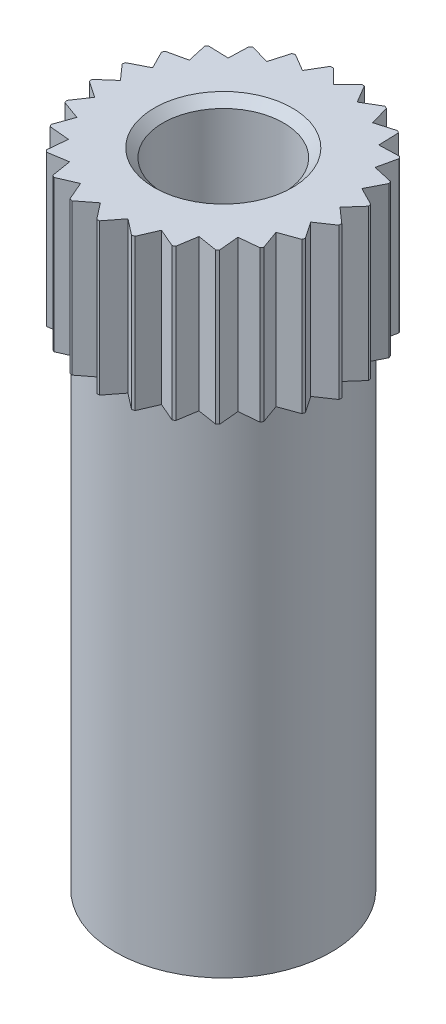
from build123d import *

# Parameters (mm, degrees)
SKETCH_1_R                  = 2.9
EXTRUDE_1_DEPTH             = 3.5
SKETCH_2_R                  = 2.5
EXTRUDE_2_DEPTH             = 11.4
CUT_EXTRUDE_1_DEPTH         = 4
HOLE_WIZARD_M32_D           = 2.8
HOLE_WIZARD_M32_DEPTH       = 6.9
HOLE_WIZARD_M32_CSINK_D     = 3.2
HOLE_WIZARD_M32_CSINK_ANGLE = 90
HOLE_WIZARD_M32_TIP         = 1.4


with BuildPart() as part:
    # Эскиз1 → Бобышка-Вытянуть1 (new body)
    with BuildSketch(Plane(origin=(0, 0, 0), x_dir=(1, 0, 0), z_dir=(0, 1, 0))):
        Circle(SKETCH_1_R)
    extrude(amount=EXTRUDE_1_DEPTH)

    # Эскиз2 → Бобышка-Вытянуть2 (add)
    with BuildSketch(Plane.XZ):
        Circle(SKETCH_2_R)
    extrude(amount=EXTRUDE_2_DEPTH)

    # Эскиз3 → Вырез-Вытянуть1 (cut)
    with BuildSketch(Plane(origin=(0, 3.5, 0), x_dir=(1, 0, 0), z_dir=(0, 1, 0))):
        Polygon((0, 2.55), (-0.366495157, 2.916495157), (0.366495157, 2.916495157), align=None)
        Polygon((0.634159212, 2.469887061), (0.370321814, 2.916011738), (1.080283889, 2.733724459), align=None)
        Polygon((1.228471869, 2.234582034), (1.083870103, 2.732304577), (1.726194412, 2.3791838), align=None)
        Polygon((1.74559512, 1.85887), (1.729314848, 2.37691667), (2.263641791, 1.875150272), align=None)
        Polygon((2.15303621, 1.366358327), (2.26610038, 1.872178348), (2.658856231, 1.253294157), align=None)
        Polygon((2.425194117, 0.787993336), (2.660498492, 1.249804175), (2.887004956, 0.55268896), align=None)
        Polygon((2.544968157, 0.160115825), (2.887727699, 0.548900209), (2.933752541, -0.182643716), align=None)
        Polygon((2.504832489, -0.477822352), (2.933510354, -0.186493176), (2.796161665, -0.906500217), align=None)
        Polygon((2.307308984, -1.085737193), (2.794969765, -0.910168509), (2.482877668, -1.573397974), align=None)
        Polygon((1.964808769, -1.625431174), (2.480810946, -1.576654607), (2.013585336, -2.141433351), align=None)
        Polygon((1.498852393, -2.062993336), (2.010773652, -2.144073698), (1.417772031, -2.574914594), align=None)
        Polygon((0.938717609, -2.370930039), (1.414392054, -2.576772752), (0.732874896, -2.846604484), align=None)
        Polygon((0.319599746, -2.529892488), (0.729139002, -2.847563698), (0.001928536, -2.939431745), align=None)
        Polygon((-0.319599746, -2.529892488), (-0.001928536, -2.939431745), (-0.729139002, -2.847563698), align=None)
        Polygon((-0.938717609, -2.370930039), (-0.732874896, -2.846604484), (-1.414392054, -2.576772752), align=None)
        Polygon((-1.498852393, -2.062993336), (-1.417772031, -2.574914594), (-2.010773652, -2.144073698), align=None)
        Polygon((-1.964808769, -1.625431174), (-2.013585336, -2.141433351), (-2.480810946, -1.576654607), align=None)
        Polygon((-2.307308984, -1.085737193), (-2.482877668, -1.573397974), (-2.794969765, -0.910168509), align=None)
        Polygon((-2.504832489, -0.477822352), (-2.796161665, -0.906500217), (-2.933510354, -0.186493176), align=None)
        Polygon((-2.544968157, 0.160115825), (-2.933752541, -0.182643716), (-2.887727699, 0.548900209), align=None)
        Polygon((-2.425194117, 0.787993336), (-2.887004956, 0.55268896), (-2.660498492, 1.249804175), align=None)
        Polygon((-2.15303621, 1.366358327), (-2.658856231, 1.253294157), (-2.26610038, 1.872178348), align=None)
        Polygon((-1.74559512, 1.85887), (-2.263641791, 1.875150272), (-1.729314848, 2.37691667), align=None)
        Polygon((-1.228471869, 2.234582034), (-1.726194412, 2.3791838), (-1.083870103, 2.732304577), align=None)
        Polygon((-0.634159212, 2.469887061), (-1.080283889, 2.733724459), (-0.370321814, 2.916011738), align=None)
    extrude(amount=-CUT_EXTRUDE_1_DEPTH, mode=Mode.SUBTRACT)

    # Сверло под метчик  спиральное M32
    with Locations(Plane(origin=(0, 3.5, 0), x_dir=(1, 0, 0), z_dir=(0, 1, 0))):
        with Locations((0, 0)):
            CounterSinkHole(HOLE_WIZARD_M32_D / 2, HOLE_WIZARD_M32_CSINK_D / 2, depth=HOLE_WIZARD_M32_DEPTH, counter_sink_angle=HOLE_WIZARD_M32_CSINK_ANGLE)
            with Locations((0, 0, -(HOLE_WIZARD_M32_DEPTH + HOLE_WIZARD_M32_TIP / 2))):  # 90° drill point
                Cone(0, HOLE_WIZARD_M32_D / 2, HOLE_WIZARD_M32_TIP, mode=Mode.SUBTRACT)


solid = part.part
